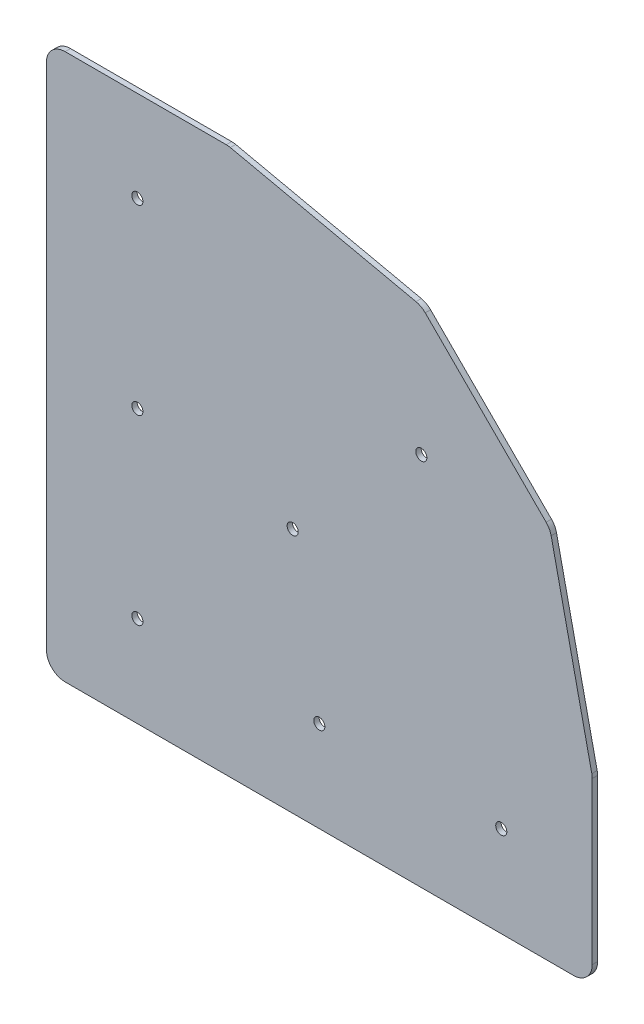
from build123d import *

# Parameters (mm, degrees)
SKETCH1_R           = 1.651
BOSS_EXTRUDE1_DEPTH = 1.5875


with BuildPart() as part:
    # Sketch1 → Boss-Extrude1 (new body)
    with BuildSketch(Plane(origin=(0, 0, 0), x_dir=(-1, 0, 0), z_dir=(0, 0, -1))):
        with BuildLine():
            Line((-156.36875, 0), (-5.55625, 0))
            ThreePointArc((-5.55625, 0), (-1.627387947, 1.627387947), (0, 5.55625))
            Line((0, 5.55625), (0, 156.368750002))
            ThreePointArc((0, 156.368750002), (-1.627387947, 160.297612055), (-5.55625, 161.925000002))
            Line((-5.55625, 161.925000002), (-53.373846022, 161.925000002))
            ThreePointArc((-53.373846022, 161.925000002), (-53.971512021, 161.892762078), (-54.562242583, 161.796422402))
            Line((-54.562242583, 161.796422402), (-109.634404321, 149.738294575))
            ThreePointArc((-109.634404321, 149.738294575), (-111.112127046, 149.185426993), (-112.374869815, 148.239484227))
            Line((-112.374869815, 148.239484227), (-148.239484217, 112.374869825))
            ThreePointArc((-148.239484217, 112.374869825), (-149.185426983, 111.112127057), (-149.738294565, 109.634404332))
            Line((-149.738294565, 109.634404332), (-161.796422399, 54.562242596))
            ThreePointArc((-161.796422399, 54.562242596), (-161.892762076, 53.971512033), (-161.925, 53.373846033))
            Line((-161.925, 53.373846033), (-161.925, 5.55625))
            ThreePointArc((-161.925, 5.55625), (-160.297612053, 1.627387947), (-156.36875, 0))
        make_face()
        with Locations((-26.9875, 134.9375)):
            Circle(SKETCH1_R, mode=Mode.SUBTRACT)
        with Locations((-26.9875, 80.9625)):
            Circle(SKETCH1_R, mode=Mode.SUBTRACT)
        with Locations((-26.9875, 26.9875)):
            Circle(SKETCH1_R, mode=Mode.SUBTRACT)
        with Locations((-134.9375, 26.9875)):
            Circle(SKETCH1_R, mode=Mode.SUBTRACT)
        with Locations((-73.058044257, 73.058044257)):
            Circle(SKETCH1_R, mode=Mode.SUBTRACT)
        with Locations((-111.224132771, 111.224132771)):
            Circle(SKETCH1_R, mode=Mode.SUBTRACT)
        with Locations((-80.9625, 26.9875)):
            Circle(SKETCH1_R, mode=Mode.SUBTRACT)
    extrude(amount=-BOSS_EXTRUDE1_DEPTH)


solid = part.part
